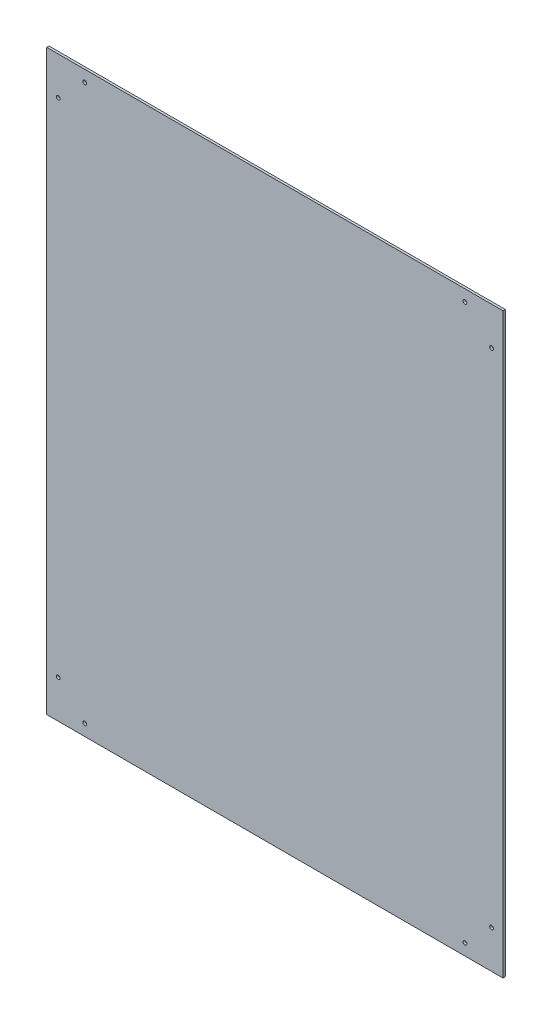
from build123d import *

# Parameters (mm, degrees)
ESQUISSE1_W             = 600
ESQUISSE1_H             = 760
BOSS_EXTRU_1_DEPTH      = 3
ESQUISSE2_R             = 2.5
ENL_V_MAT_EXTRU_1_DEPTH = 3


with BuildPart() as part:
    # Esquisse1 → Boss.-Extru.1 (new body)
    with BuildSketch(Plane.XY):
        with Locations((300, 380)):
            Rectangle(ESQUISSE1_W, ESQUISSE1_H)
    extrude(amount=BOSS_EXTRU_1_DEPTH)

    # Esquisse2 → Enlèv. mat.-Extru.1 (cut)
    with BuildSketch(Plane.XY.offset(3)):
        with Locations((50, 745)):
            Circle(ESQUISSE2_R)
        with Locations((15, 710)):
            Circle(ESQUISSE2_R)
        with Locations((15, 50)):
            Circle(ESQUISSE2_R)
        with Locations((50, 15)):
            Circle(ESQUISSE2_R)
        with Locations((550, 15)):
            Circle(ESQUISSE2_R)
        with Locations((585, 50)):
            Circle(ESQUISSE2_R)
        with Locations((585, 710)):
            Circle(ESQUISSE2_R)
        with Locations((550, 745)):
            Circle(ESQUISSE2_R)
    extrude(amount=-ENL_V_MAT_EXTRU_1_DEPTH, mode=Mode.SUBTRACT)


solid = part.part
